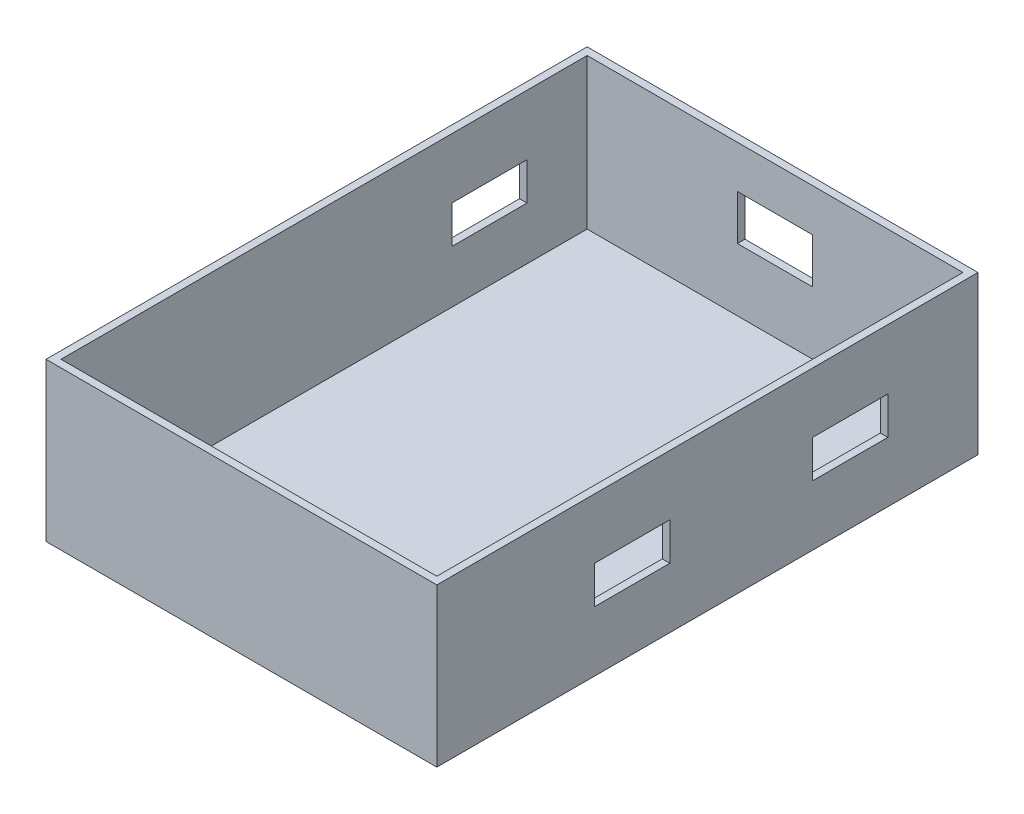
from build123d import *

# Parameters (mm, degrees)
CROQUIS1_W              = 50
CROQUIS1_H              = 70
SALIENTE_EXTRUIR1_DEPTH = 1
CROQUIS1_3_W            = 52
CROQUIS1_3_H            = 72
CROQUIS1_3_W_2          = 50
CROQUIS1_3_H_2          = 70
SALIENTE_EXTRUIR2_DEPTH = 21
CROQUIS3_W              = 10
CROQUIS3_H              = 6
CORTAR_EXTRUIR1_DEPTH   = 21
CROQUIS4_W              = 10
CROQUIS4_H              = 5
CORTAR_EXTRUIR3_DEPTH   = 29
CROQUIS5_W              = 10
CROQUIS5_H              = 5
CORTAR_EXTRUIR4_DEPTH   = 29


with BuildPart() as part:
    # Croquis1 → Saliente-Extruir1 (new body)
    with BuildSketch(Plane(origin=(0, 0, 0), x_dir=(1, 0, 0), z_dir=(0, 1, 0))):
        with Locations((25, 35)):
            Rectangle(CROQUIS1_W, CROQUIS1_H)
    extrude(amount=SALIENTE_EXTRUIR1_DEPTH)

    # Croquis1_3 → Saliente-Extruir2 (add)
    with BuildSketch(Plane(origin=(0, 0, 0), x_dir=(1, 0, 0), z_dir=(0, 1, 0))):
        with Locations((25, 35)):
            Rectangle(CROQUIS1_3_W, CROQUIS1_3_H)
        with Locations((25, 35)):
            Rectangle(CROQUIS1_3_W_2, CROQUIS1_3_H_2, mode=Mode.SUBTRACT)
    extrude(amount=SALIENTE_EXTRUIR2_DEPTH)

    # Croquis3 → Cortar-Extruir1 (cut)
    with BuildSketch(Plane(origin=(0, 0, -71), x_dir=(-1, 0, 0), z_dir=(0, 0, -1))):
        with Locations((-25, 12.33)):
            Rectangle(CROQUIS3_W, CROQUIS3_H)
    extrude(amount=-CORTAR_EXTRUIR1_DEPTH, mode=Mode.SUBTRACT)

    # Croquis4 → Cortar-Extruir3 (cut)
    with BuildSketch(Plane(origin=(51, 0, 0), x_dir=(0, 0, -1), z_dir=(1, 0, 0))):
        with Locations((25, 10.5)):
            Rectangle(CROQUIS4_W, CROQUIS4_H)
        with Locations((54, 10.5)):
            Rectangle(CROQUIS4_W, CROQUIS4_H)
    extrude(amount=-CORTAR_EXTRUIR3_DEPTH, mode=Mode.SUBTRACT)

    # Croquis5 → Cortar-Extruir4 (cut)
    with BuildSketch(Plane.ZY.offset(1)):
        with Locations((-57, 10.5)):
            Rectangle(CROQUIS5_W, CROQUIS5_H)
    extrude(amount=-CORTAR_EXTRUIR4_DEPTH, mode=Mode.SUBTRACT)


solid = part.part
